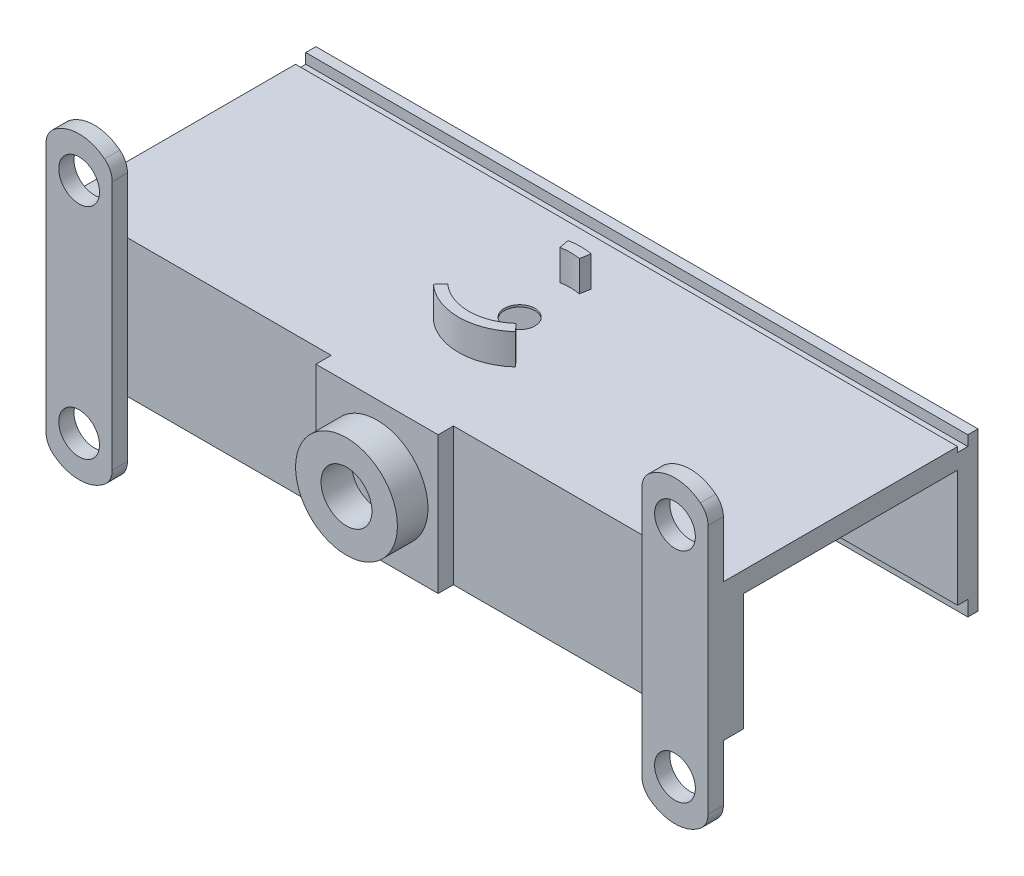
from build123d import *

# Parameters (mm, degrees)
CROQUIS1_W               = 65
CROQUIS1_H               = 25
SALIENTE_EXTRUIR4_DEPTH  = 13.5
CROQUIS6_W               = 21
CROQUIS6_H               = 11.5
CORTAR_EXTRUIR2_DEPTH    = 65
CROQUIS5_R               = 2
SALIENTE_EXTRUIR6_DEPTH  = 1.5
CROQUIS7_W               = 12
CROQUIS7_H               = 13.5
SALIENTE_EXTRUIR7_DEPTH  = 1.5
CROQUIS8_R               = 5
SALIENTE_EXTRUIR8_DEPTH  = 3
CROQUIS9_R               = 2.5
CORTAR_EXTRUIR3_DEPTH    = 3
CROQUIS10_W              = 6
CROQUIS10_H              = 2
CORTAR_EXTRUIR4_DEPTH    = 10
CROQUIS11_R              = 1.5
CORTAR_EXTRUIR5_DEPTH    = 10
CROQUIS12_R              = 2
CORTAR_EXTRUIR6_DEPTH    = 10
CORTAR_EXTRUIR7_DEPTH    = 2
CROQUIS15_R              = 1.5
CORTAR_EXTRUIR8_DEPTH    = 2
CROQUIS18_R              = 6.5
CORTAR_EXTRUIR9_DEPTH    = 1.8
SALIENTE_EXTRUIR9_DEPTH  = 3
CROQUIS20_W              = 65
CROQUIS20_H              = 1
SALIENTE_EXTRUIR10_DEPTH = 1.5
CROQUIS21_W              = 65
CROQUIS21_H              = 1
SALIENTE_EXTRUIR11_DEPTH = 0.5
CROQUIS22_W              = 65
CROQUIS22_H              = 1
CORTAR_EXTRUIR10_DEPTH   = 0.5


with BuildPart() as part:
    # Croquis1 → Saliente-Extruir4 (new body)
    with BuildSketch(Plane(origin=(0, 0, 0), x_dir=(1, 0, 0), z_dir=(0, 1, 0))):
        with Locations((0, -12.5)):
            Rectangle(CROQUIS1_W, CROQUIS1_H)
    extrude(amount=SALIENTE_EXTRUIR4_DEPTH)

    # Croquis6 → Cortar-Extruir2 (cut)
    with BuildSketch(Plane(origin=(32.5, 0, 0), x_dir=(0, 0, -1), z_dir=(1, 0, 0))):
        with Locations((-12.5, 5.75)):
            Rectangle(CROQUIS6_W, CROQUIS6_H)
    extrude(amount=-CORTAR_EXTRUIR2_DEPTH, mode=Mode.SUBTRACT)

    # Croquis5 → Saliente-Extruir6 (add)
    with BuildSketch(Plane.XY.offset(25)):
        with BuildLine():
            Line((32.5, 0), (32.5, -5.518414164))
            ThreePointArc((32.5, -5.518414164), (32.302775638, -6.384439567), (31.75, -7.079663663))
            ThreePointArc((31.75, -7.079663663), (29.25, -7.957164664), (26.75, -7.079663663))
            ThreePointArc((26.75, -7.079663663), (26.197224362, -6.384439567), (26, -5.518414164))
            Line((26, -5.518414164), (26, 0))
            Line((26, 0), (26, 13.5))
            Line((26, 13.5), (26, 19.018414164))
            ThreePointArc((26, 19.018414164), (26.197224362, 19.884439567), (26.75, 20.579663663))
            ThreePointArc((26.75, 20.579663663), (29.25, 21.457164664), (31.75, 20.579663663))
            ThreePointArc((31.75, 20.579663663), (32.302775638, 19.884439567), (32.5, 19.018414164))
            Line((32.5, 19.018414164), (32.5, 13.5))
            Line((32.5, 13.5), (32.5, 0))
        make_face()
        with Locations((29.25, 17.457164664)):
            Circle(CROQUIS5_R, mode=Mode.SUBTRACT)
        with Locations((29.25, -3.957164664)):
            Circle(CROQUIS5_R, mode=Mode.SUBTRACT)
        with BuildLine():
            Line((-32.5, 0), (-32.5, -5.518414164))
            ThreePointArc((-32.5, -5.518414164), (-32.302775638, -6.384439567), (-31.75, -7.079663663))
            ThreePointArc((-31.75, -7.079663663), (-29.25, -7.957164664), (-26.75, -7.079663663))
            ThreePointArc((-26.75, -7.079663663), (-26.197224362, -6.384439567), (-26, -5.518414164))
            Line((-26, -5.518414164), (-26, 0))
            Line((-26, 0), (-26, 13.5))
            Line((-26, 13.5), (-26, 19.018414164))
            ThreePointArc((-26, 19.018414164), (-26.197224362, 19.884439567), (-26.75, 20.579663663))
            ThreePointArc((-26.75, 20.579663663), (-29.25, 21.457164664), (-31.75, 20.579663663))
            ThreePointArc((-31.75, 20.579663663), (-32.302775638, 19.884439567), (-32.5, 19.018414164))
            Line((-32.5, 19.018414164), (-32.5, 13.5))
            Line((-32.5, 13.5), (-32.5, 0))
        make_face()
    extrude(amount=SALIENTE_EXTRUIR6_DEPTH)

    # Croquis7 → Saliente-Extruir7 (add)
    with BuildSketch(Plane.XY.offset(25)):
        with Locations((0, 6.75)):
            Rectangle(CROQUIS7_W, CROQUIS7_H)
    extrude(amount=SALIENTE_EXTRUIR7_DEPTH)

    # Croquis8 → Saliente-Extruir8 (add)
    with BuildSketch(Plane.XY.offset(26.5)):
        with Locations((0, 6.75)):
            Circle(CROQUIS8_R)
    extrude(amount=SALIENTE_EXTRUIR8_DEPTH)

    # Croquis9 → Cortar-Extruir3 (cut)
    with BuildSketch(Plane.XY.offset(29.5)):
        with Locations((0, 6.75)):
            Circle(CROQUIS9_R)
    extrude(amount=-CORTAR_EXTRUIR3_DEPTH, mode=Mode.SUBTRACT)

    # Croquis10 → Cortar-Extruir4 (cut)
    with BuildSketch(Plane.XZ):
        with Locations((0, 24)):
            Rectangle(CROQUIS10_W, CROQUIS10_H)
    extrude(amount=-CORTAR_EXTRUIR4_DEPTH, mode=Mode.SUBTRACT)

    # Croquis11 → Cortar-Extruir5 (cut)
    with BuildSketch(Plane.XY.offset(26.5)):
        with Locations((0, 6.75)):
            Circle(CROQUIS11_R)
    extrude(amount=-CORTAR_EXTRUIR5_DEPTH, mode=Mode.SUBTRACT)

    # Croquis12 → Cortar-Extruir6 (cut)
    with BuildSketch(Plane.XY.offset(26.5)):
        with Locations((-29.25, 17.5)):
            Circle(CROQUIS12_R)
        with Locations((-29.25, -4)):
            Circle(CROQUIS12_R)
    extrude(amount=-CORTAR_EXTRUIR6_DEPTH, mode=Mode.SUBTRACT)

    # Croquis14 → Cortar-Extruir7 (cut)
    with BuildSketch(Plane(origin=(0, 0, 23), x_dir=(-1, 0, 0), z_dir=(0, 0, -1))):
        with BuildLine():
            Line((-3, 10), (-3, 10.5))
            ThreePointArc((-3, 10.5), (-2.707106781, 11.207106781), (-2, 11.5))
            Line((-2, 11.5), (2, 11.5))
            ThreePointArc((2, 11.5), (2.707106781, 11.207106781), (3, 10.5))
            Line((3, 10.5), (3, 10))
            Line((3, 10), (-3, 10))
        make_face()
    extrude(amount=-CORTAR_EXTRUIR7_DEPTH, mode=Mode.SUBTRACT)

    # Croquis15 → Cortar-Extruir8 (cut)
    with BuildSketch(Plane.XZ.offset(-11.5)):
        with Locations((0, 12.5)):
            Circle(CROQUIS15_R)
    extrude(amount=-CORTAR_EXTRUIR8_DEPTH, mode=Mode.SUBTRACT)

    # Croquis18 → Cortar-Extruir9 (cut)
    with BuildSketch(Plane.XZ.offset(-11.5)):
        with Locations((0, 12.5)):
            Circle(CROQUIS18_R)
    extrude(amount=-CORTAR_EXTRUIR9_DEPTH, mode=Mode.SUBTRACT)

    # Croquis19 → Saliente-Extruir9 (add)
    with BuildSketch(Plane(origin=(0, 13.5, 0), x_dir=(1, 0, 0), z_dir=(0, 1, 0))):
        with BuildLine():
            Line((-3.359531229, -16.203181054), (-4.031437475, -16.943817265))
            ThreePointArc((-4.031437475, -16.943817265), (0, -18.5), (4.031437475, -16.943817265))
            Line((4.031437475, -16.943817265), (3.359531229, -16.203181054))
            ThreePointArc((3.359531229, -16.203181054), (0, -17.5), (-3.359531229, -16.203181054))
        make_face()
        with BuildLine():
            Line((-1.132967397, -6.607938826), (-0.944139498, -7.589949022))
            ThreePointArc((-0.944139498, -7.589949022), (0, -7.5), (0.944139498, -7.589949022))
            Line((0.944139498, -7.589949022), (1.132967397, -6.607938826))
            ThreePointArc((1.132967397, -6.607938826), (0, -6.5), (-1.132967397, -6.607938826))
        make_face()
    extrude(amount=SALIENTE_EXTRUIR9_DEPTH)

    # Croquis20 → Saliente-Extruir10 (add)
    with BuildSketch(Plane.XZ):
        with Locations((0, 0.5)):
            Rectangle(CROQUIS20_W, CROQUIS20_H)
    extrude(amount=SALIENTE_EXTRUIR10_DEPTH)

    # Croquis21 → Saliente-Extruir11 (add)
    with BuildSketch(Plane(origin=(0, 13.5, 0), x_dir=(1, 0, 0), z_dir=(0, 1, 0))):
        with Locations((0, -0.5)):
            Rectangle(CROQUIS21_W, CROQUIS21_H)
    extrude(amount=SALIENTE_EXTRUIR11_DEPTH)

    # Croquis22 → Cortar-Extruir10 (cut)
    with BuildSketch(Plane(origin=(0, 13.5, 0), x_dir=(1, 0, 0), z_dir=(0, 1, 0))):
        with Locations((0, -1.5)):
            Rectangle(CROQUIS22_W, CROQUIS22_H)
    extrude(amount=-CORTAR_EXTRUIR10_DEPTH, mode=Mode.SUBTRACT)


solid = part.part
